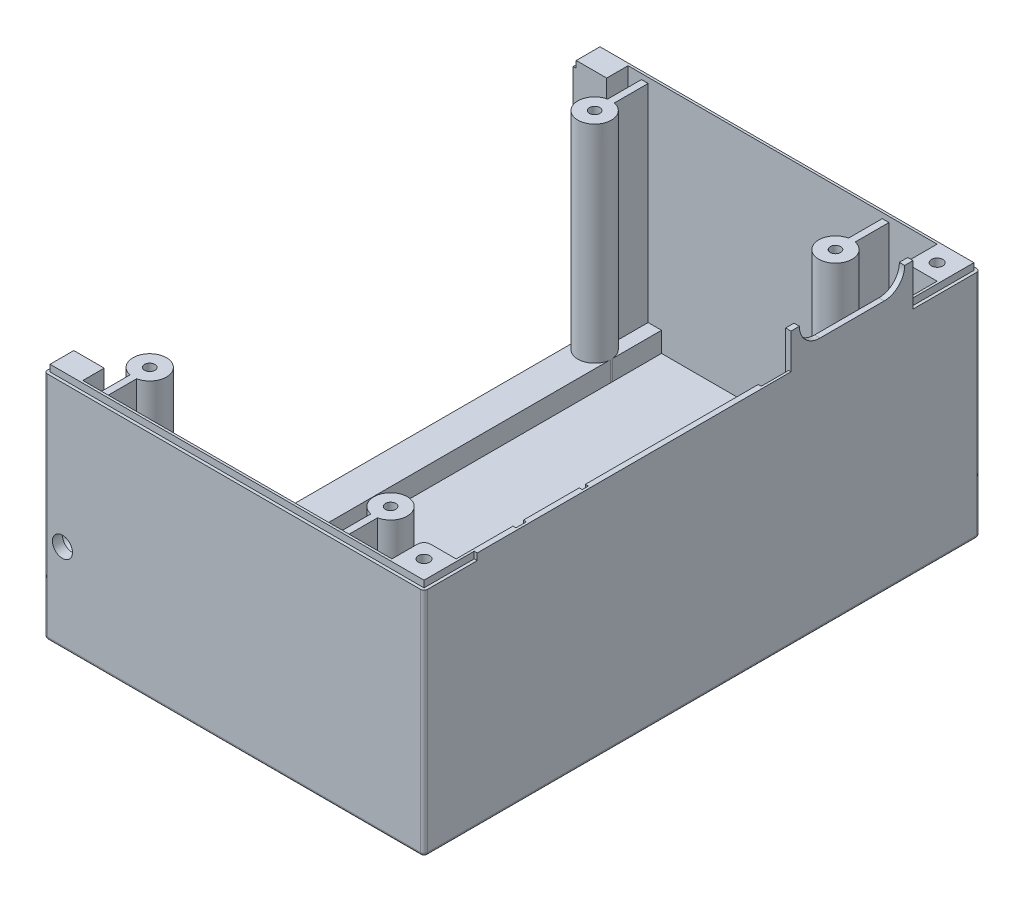
from build123d import *

# Parameters (mm, degrees)
SKETCH_1_W                    = 113.6
SKETCH_1_H                    = 166.2
EXTRUDE_1_DEPTH               = 1.6
EXTRUDE_2_DEPTH               = 69.5
SKETCH_3_W                    = 10
SKETCH_3_H                    = 163
EXTRUDE_3_DEPTH               = 6
SKETCH_20_R                   = 5
EXTRUDE_7_DEPTH               = 67.9
SKETCH_25_W                   = 9.6
SKETCH_25_H                   = 9.6
EXTRUDE_8_DEPTH               = 69.5
SKETCH_27_R                   = 1.55
CUT_EXTRUDE_1_DEPTH           = 6
EXTRUDE_9_DEPTH               = 1.6
SKETCH_30_R                   = 3.2
CUT_EXTRUDE_2_DEPTH           = 65.5
SKETCH_38_R                   = 1.7
CUT_EXTRUDE_9_DEPTH           = 3.9
SKETCH_31_R                   = 2.8
PATTERN_LINEAR_3_COUNT        = 2
PATTERN_LINEAR_3_PITCH        = 153.4
CUT_EXTRUDE_8_DEPTH           = 2
SKETCH_50_W                   = 0.9
SKETCH_50_H                   = 8.175007394
SKETCH_50_H_2                 = 1.824993516
SKETCH_50_H_3                 = 3.100006964
CUT_EXTRUDE_14_DEPTH          = 2
SKETCH_40_W                   = 5.2
SKETCH_40_H                   = 150.2
CUT_EXTRUDE_10_DEPTH          = 1.6
FILLET_2_R                    = 2
FILLET_3_R                    = 1
EXTRUDE_13_DEPTH              = 61.9
PATTERN_LINEAR_4_COUNT        = 2
PATTERN_LINEAR_4_PITCH        = 72
PATTERN_LINEAR_4_COPY_1_DEPTH = 61.9
SKETCH_17_R                   = 1.55
CUT_EXTRUDE_13_DEPTH          = 6
FILLET_4_R                    = 1


with BuildPart() as part:
    # Эскиз1 → Бобышка-Вытянуть1 (new body)
    with BuildSketch(Plane(origin=(0, 0, 0), x_dir=(1, 0, 0), z_dir=(0, 1, 0))):
        with Locations((-2.6, 0)):
            Rectangle(SKETCH_1_W, SKETCH_1_H)
    extrude(amount=-EXTRUDE_1_DEPTH)

    # Эскиз2 → Бобышка-Вытянуть2 (add)
    with BuildSketch(Plane(origin=(0, 0, 0), x_dir=(1, 0, 0), z_dir=(0, 1, 0))):
        Polygon((-54.2, 83.1), (54.2, 83.1), (54.2, -83.1), (-59.4, -83.1), (-59.4, -75.1), (-49.4, -75.1), (-49.4, -81.5), (52.6, -81.5), (52.6, 81.5), (-49.4, 81.5), (-49.4, 75.1), (-59.4, 75.1), (-59.4, 83.1), align=None)
    extrude(amount=EXTRUDE_2_DEPTH)

    # Эскиз3 → Бобышка-Вытянуть3 (add)
    with BuildSketch(Plane(origin=(0, 0, 0), x_dir=(1, 0, 0), z_dir=(0, 1, 0))):
        with Locations((27.6, 0)):
            Rectangle(SKETCH_3_W, SKETCH_3_H)
        with Locations((-44.4, 0)):
            Rectangle(SKETCH_3_W, SKETCH_3_H)
    extrude(amount=EXTRUDE_3_DEPTH)

    # Эскиз20 → Бобышка-Вытянуть7 (add)
    with BuildSketch(Plane(origin=(0, 0, 0), x_dir=(1, 0, 0), z_dir=(0, 1, 0))):
        with Locations(Location((-44.4, -66.5, 0), (0, 0, 180))):
            Circle(SKETCH_20_R)
        with Locations(Location((-44.390159066, 66.5, 0), (0, 0, 3.595357258))):
            Circle(SKETCH_20_R)
        with Locations(Location((27.6, 66.5, 0), (0, 0, 180))):
            Circle(SKETCH_20_R)
        with Locations(Location((27.6, -66.5, 0), (0, 0, 180))):
            Circle(SKETCH_20_R)
    extrude(amount=EXTRUDE_7_DEPTH)

    # Эскиз25 → Бобышка-Вытянуть8 (add)
    with BuildSketch(Plane(origin=(0, 0, 0), x_dir=(1, 0, 0), z_dir=(0, 1, 0))):
        with Locations((47.8, -76.7)):
            Rectangle(SKETCH_25_W, SKETCH_25_H)
        with Locations((47.8, 76.7)):
            Rectangle(SKETCH_25_W, SKETCH_25_H)
    extrude(amount=EXTRUDE_8_DEPTH)

    # Эскиз27 → Вырез-Вытянуть1 (cut)
    with BuildSketch(Plane(origin=(0, 67.9, 0), x_dir=(1, 0, 0), z_dir=(0, 1, 0))):
        with Locations(Location((-44.390159066, 66.5, 0), (0, 0, 270))):
            Circle(SKETCH_27_R)
        with Locations(Location((27.6, 66.5, 0), (0, 0, 270))):
            Circle(SKETCH_27_R)
        with Locations(Location((27.6, -66.5, 0), (0, 0, 270))):
            Circle(SKETCH_27_R)
        with Locations(Location((-44.4, -66.5, 0), (0, 0, 270))):
            Circle(SKETCH_27_R)
    extrude(amount=-CUT_EXTRUDE_1_DEPTH, mode=Mode.SUBTRACT)

    # Эскиз29 → Бобышка-Вытянуть9 (add)
    with BuildSketch(Plane(origin=(54.2, 0, 0), x_dir=(0, 0, -1), z_dir=(1, 0, 0))):
        with BuildLine():
            Line((35.331444881, 73.9), (54.368567283, 73.9))
            Line((54.368567283, 73.9), (54.458567283, 73.9))
            ThreePointArc((54.458567283, 73.9), (58.801220304, 75.698785778), (60.600006082, 80.041438799))
            Line((60.600006082, 80.041438799), (63.100006082, 80.041438799))
            Line((63.100006082, 80.041438799), (63.100006082, 69.5))
            Line((63.100006082, 69.5), (26.600006082, 69.5))
            Line((26.600006082, 69.5), (26.600006082, 80.041438799))
            Line((26.600006082, 80.041438799), (29.100006082, 80.041438799))
            ThreePointArc((29.100006082, 80.041438799), (30.89879186, 75.698785778), (35.241444881, 73.9))
            Line((35.241444881, 73.9), (35.331444881, 73.9))
        make_face()
    extrude(amount=-EXTRUDE_9_DEPTH)

    # Эскиз30 → Вырез-Вытянуть2 (cut)
    with BuildSketch(Plane.XZ.offset(1.6)):
        with Locations(Location((47.8, -76.7, 0), (0, 0, 270))):
            Circle(SKETCH_30_R)
    cut_extrude_2 = extrude(amount=-CUT_EXTRUDE_2_DEPTH, mode=Mode.SUBTRACT)

    # Эскиз38 → Вырез-Вытянуть9 (cut)
    with BuildSketch(Plane(origin=(0, 69.5, 0), x_dir=(1, 0, 0), z_dir=(0, 1, 0))):
        with Locations(Location((47.8, 76.7, 0), (0, 0, 270))):
            Circle(SKETCH_38_R)
    cut_extrude_9 = extrude(amount=-CUT_EXTRUDE_9_DEPTH, mode=Mode.SUBTRACT)

    # Эскиз31 → section 1 of loft_1
    with BuildSketch(Plane.XZ.offset(-63.9), mode=Mode.PRIVATE) as loft_1_s1:
        with Locations((47.8, -76.7)):
            Circle(SKETCH_31_R)
    # loft up to a face of the part (loft_1)
    loft_1 = loft([Face(Wire([part.edges().sort_by_distance((49.039246667, 65.6, -77.86373008))[0]])), loft_1_s1.sketch], mode=Mode.SUBTRACT)

    # Линейный массив3: Вырез-Вытянуть2, Вырез-Вытянуть9, Вырез-По сечениям1 ×2
    with Locations(*[(0, 0, i * PATTERN_LINEAR_3_PITCH) for i in range(1, PATTERN_LINEAR_3_COUNT)]):
        add(cut_extrude_2, mode=Mode.SUBTRACT)
        add(cut_extrude_9, mode=Mode.SUBTRACT)
        add(loft_1, mode=Mode.SUBTRACT)

    # Эскиз36 → Вырез-Вытянуть8 (cut)
    with BuildSketch(Plane(origin=(0, 69.5, 0), x_dir=(1, 0, 0), z_dir=(0, 1, 0))):
        Polygon((54.2, -82.4), (54.2, -83.1), (-54.2, -83.1), (-59.4, -83.1), (-59.4, -75.1), (-58.5, -75.1), (-58.5, -82.20017947), (-52.6, -82.20017947), (53.3, -82.20017947), (53.3, -67.20000355), (54.2, -67.20000355), align=None)
        Polygon((-54.2, 83.1), (54.2, 83.1), (54.2, 63.100006082), (53.3, 63.100006082), (53.3, 82.2), (-58.5, 82.2), (-58.5, 75.1), (-59.4, 75.1), (-59.4, 83.1), align=None)
    extrude(amount=-CUT_EXTRUDE_8_DEPTH, mode=Mode.SUBTRACT)

    # Эскиз50 → Вырез-Вытянуть14 (cut)
    with BuildSketch(Plane(origin=(0, 69.5, 0), x_dir=(1, 0, 0), z_dir=(0, 1, 0))):
        with Locations((53.05, 22.512502385)):
            Rectangle(SKETCH_50_W, SKETCH_50_H)
        with Locations((53.05, -34.18749901)):
            Rectangle(SKETCH_50_W, SKETCH_50_H_2)
        with Locations((53.05, -53.34999907)):
            Rectangle(SKETCH_50_W, SKETCH_50_H_3)
    extrude(amount=-CUT_EXTRUDE_14_DEPTH, mode=Mode.SUBTRACT)

    # Эскиз40 → Вырез-Вытянуть10 (cut)
    with BuildSketch(Plane(origin=(0, 0, 0), x_dir=(1, 0, 0), z_dir=(0, 1, 0))):
        with Locations((-56.8, 0)):
            Rectangle(SKETCH_40_W, SKETCH_40_H)
    extrude(amount=-CUT_EXTRUDE_10_DEPTH, mode=Mode.SUBTRACT)

    # Эскиз48 → Отверстие1 (revolve, cut)
    with BuildSketch(Plane(origin=(-53.9, 25, 83.1), x_dir=(0, -1, 0), z_dir=(1, 0, 0))):
        Polygon((0, 0), (0, 9), (1.55, 8.068666041), (1.55, 4.45), (3, 3), (3, 0), align=None)
    hole_wizard_1 = revolve(axis=Axis((-53.9, 25, 89.230023899), (0, 0, -1)), mode=Mode.SUBTRACT)

    # Зеркальное отражение5: Отверстие1 across plane
    add(hole_wizard_1.mirror(Plane.XY), mode=Mode.SUBTRACT)

    # Скругление2
    fillet_2_edges = [part.edges().sort_by_distance(p)[0] for p in [
        (43, 34.75, -71.9),
        (43, 34.75, 71.9),
    ]]
    fillet(fillet_2_edges, radius=FILLET_2_R)

    # Скругление3
    fillet_3_edges = [part.edges().sort_by_distance(p)[0] for p in [
        (54.2, 32.95, -83.1),
        (54.2, 32.95, 83.1),
        (-59.4, 32.95, 83.1),
        (-59.4, 32.95, -83.1),
    ]]
    fillet(fillet_3_edges, radius=FILLET_3_R)

    # Эскиз46 → Бобышка-Вытянуть13 (add)
    with BuildSketch(Plane(origin=(0, 6, 0), x_dir=(1, 0, 0), z_dir=(0, 1, 0))):
        Polygon((-45.4, 81.5), (-45.4, 71.396960413), (-43.4, 71.400977966), (-43.4, 81.5), align=None)
    extrude_13 = extrude(amount=EXTRUDE_13_DEPTH)

    # Зеркальное отражение4: Бобышка-Вытянуть13 across plane
    add(extrude_13.mirror(Plane.XY))

    # Линейный массив4: Бобышка-Вытянуть13 ×2
    with Locations(*[(i * PATTERN_LINEAR_4_PITCH, 0, 0) for i in range(1, PATTERN_LINEAR_4_COUNT)]):
        add(extrude_13)

    # Линейный массив4 copy 1 sketch → Линейный массив4 copy 1 (add)
    with BuildSketch(Plane(origin=(72, 6, 0), x_dir=(1, 0, 0), z_dir=(0, 1, 0))):
        Polygon((-45.4, -81.5), (-45.4, -71.396960413), (-43.4, -71.400977966), (-43.4, -81.5), align=None)
    extrude(amount=PATTERN_LINEAR_4_COPY_1_DEPTH)

    # Эскиз17 → Вырез-Вытянуть13 (cut)
    with BuildSketch(Plane(origin=(0, 6, 0), x_dir=(1, 0, 0), z_dir=(0, 1, 0))):
        with Locations(Location((27.1, 46.25, 0), (0, 0, 270))):
            Circle(SKETCH_17_R)
        with Locations(Location((-42.9, -46.25, 0), (0, 0, 270))):
            Circle(SKETCH_17_R)
    extrude(amount=-CUT_EXTRUDE_13_DEPTH, mode=Mode.SUBTRACT)

    # Скругление4
    fillet_4_edges = [part.edges().sort_by_distance(p)[0] for p in [
        (-59.4, -1.6, 78.6),
        (-2.6, -1.6, -83.1),
        (-59.4, -1.6, -78.6),
        (54.2, -1.6, 0),
        (-2.6, -1.6, 83.1),
        (-59.107106781, -1.6, 82.807106781),
        (53.907106781, -1.6, 82.807106781),
        (53.907106781, -1.6, -82.807106781),
        (-59.107106781, -1.6, -82.807106781),
    ]]
    fillet(fillet_4_edges, radius=FILLET_4_R)


solid = part.part
